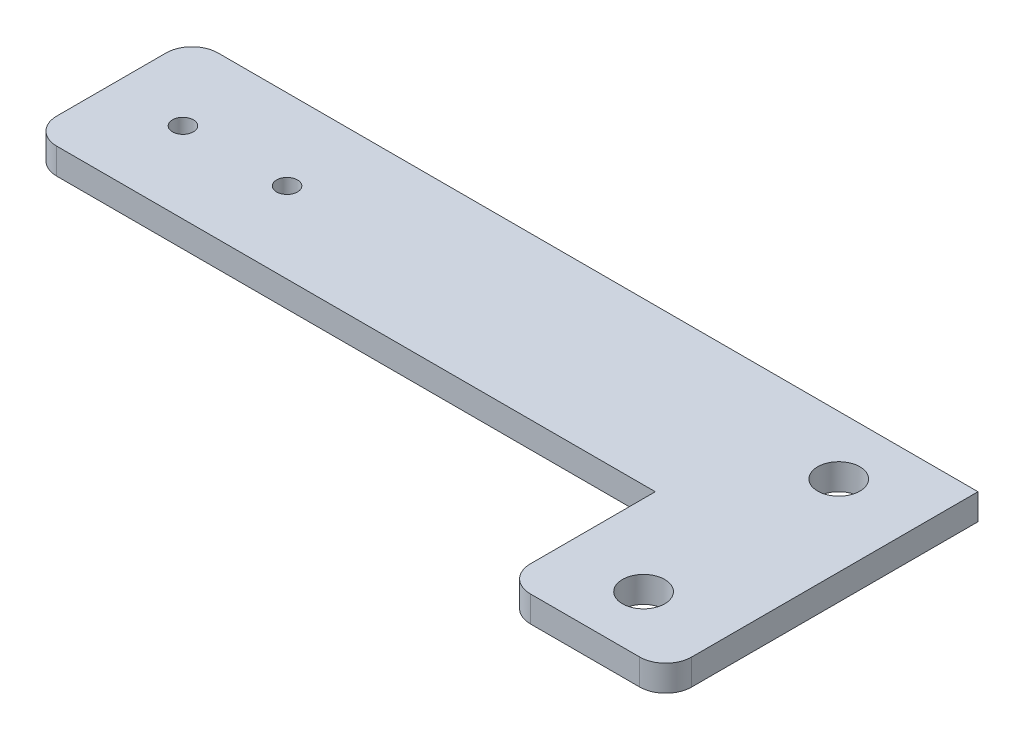
from build123d import *

# Parameters (mm, degrees)
BOSS_EXTRUDE1_DEPTH = 6.35
CUT_EXTRUDE1_REACH  = 8.35
SKETCH4_R           = 2.5527
SKETCH4_R_2         = 5.1562
FILLET1_R           = 6.35


with BuildPart() as part:
    # Sketch3 → Boss-Extrude1 (new body)
    with BuildSketch(Plane(origin=(0, 0, 0), x_dir=(1, 0, 0), z_dir=(0, 1, 0))):
        Polygon((0, 0), (191.77, 0), (191.77, -76.2), (152.4, -76.2), (152.4, -39.37), (0, -39.37), align=None)
    extrude(amount=BOSS_EXTRUDE1_DEPTH)

    # Sketch4 → Cut-Extrude1 (cut, up to next)
    with BuildSketch(Plane(origin=(0, 6.35, 0), x_dir=(1, 0, 0), z_dir=(0, 1, 0)), mode=Mode.PRIVATE) as cut_extrude1_sk1:
        with Locations((17.4625, -19.685)):
            Circle(SKETCH4_R)
    cut_extrude1_tool1 = extrude(cut_extrude1_sk1.sketch, amount=-CUT_EXTRUDE1_REACH, mode=Mode.PRIVATE) & part.part
    add(cut_extrude1_tool1.solids().sort_by_distance((17.4625, 6.35, 19.685))[0], mode=Mode.SUBTRACT)
    # Sketch4 → Cut-Extrude1 (cut, up to next)
    with BuildSketch(Plane(origin=(0, 6.35, 0), x_dir=(1, 0, 0), z_dir=(0, 1, 0)), mode=Mode.PRIVATE) as cut_extrude1_sk2:
        with Locations((42.8625, -19.685)):
            Circle(SKETCH4_R)
    cut_extrude1_tool2 = extrude(cut_extrude1_sk2.sketch, amount=-CUT_EXTRUDE1_REACH, mode=Mode.PRIVATE) & part.part
    add(cut_extrude1_tool2.solids().sort_by_distance((42.8625, 6.35, 19.685))[0], mode=Mode.SUBTRACT)
    # Sketch4 → Cut-Extrude1 (cut, up to next)
    with BuildSketch(Plane(origin=(0, 6.35, 0), x_dir=(1, 0, 0), z_dir=(0, 1, 0)), mode=Mode.PRIVATE) as cut_extrude1_sk3:
        with Locations((172.085, -14.2875)):
            Circle(SKETCH4_R_2)
    cut_extrude1_tool3 = extrude(cut_extrude1_sk3.sketch, amount=-CUT_EXTRUDE1_REACH, mode=Mode.PRIVATE) & part.part
    add(cut_extrude1_tool3.solids().sort_by_distance((172.085, 6.35, 14.2875))[0], mode=Mode.SUBTRACT)
    # Sketch4 → Cut-Extrude1 (cut, up to next)
    with BuildSketch(Plane(origin=(0, 6.35, 0), x_dir=(1, 0, 0), z_dir=(0, 1, 0)), mode=Mode.PRIVATE) as cut_extrude1_sk4:
        with Locations((172.085, -61.9125)):
            Circle(SKETCH4_R_2)
    cut_extrude1_tool4 = extrude(cut_extrude1_sk4.sketch, amount=-CUT_EXTRUDE1_REACH, mode=Mode.PRIVATE) & part.part
    add(cut_extrude1_tool4.solids().sort_by_distance((172.085, 6.35, 61.9125))[0], mode=Mode.SUBTRACT)

    # Fillet1
    fillet1_edges = [part.edges().sort_by_distance(p)[0] for p in [
        (0, 3.175, 0),
        (191.77, 3.175, 76.2),
        (152.4, 3.175, 76.2),
        (0, 3.175, 39.37),
    ]]
    fillet(fillet1_edges, radius=FILLET1_R)


solid = part.part
